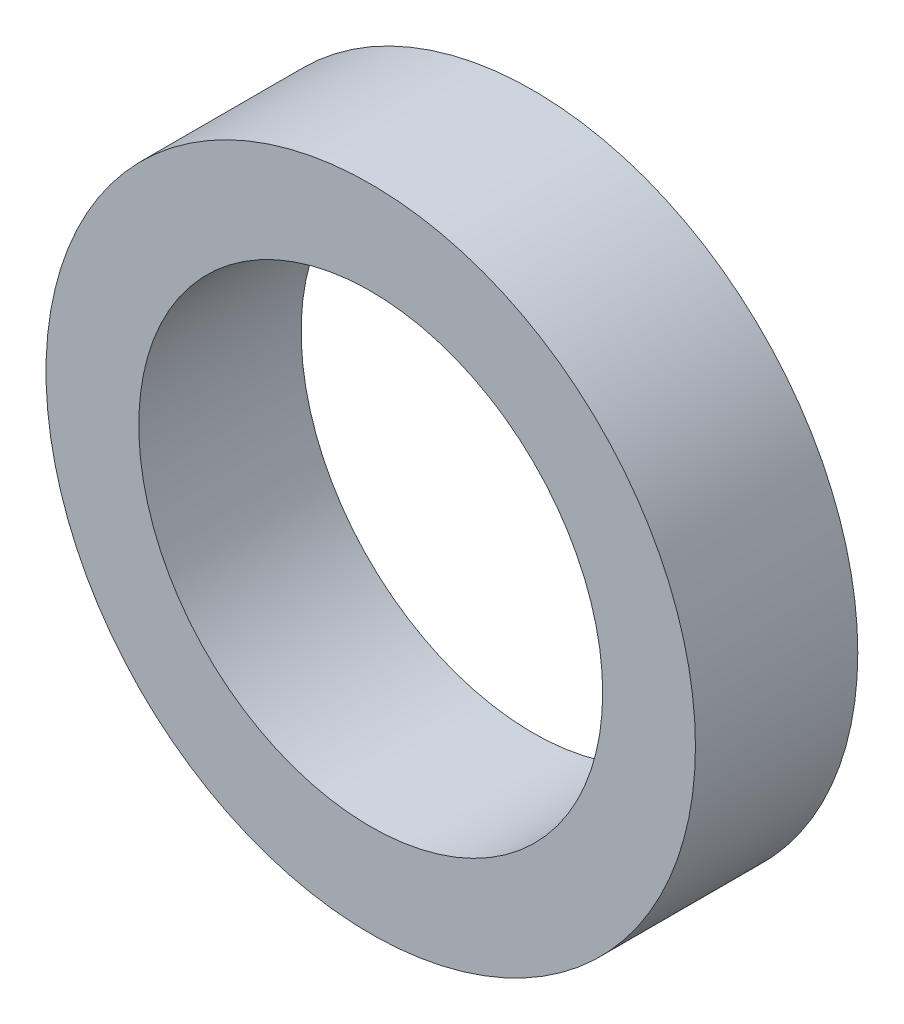
from build123d import *

# Parameters (mm, degrees)
SKETCH1_R           = 20
SKETCH1_R_2         = 14.2875
BOSS_EXTRUDE1_DEPTH = 10


with BuildPart() as part:
    # Sketch1 → Boss-Extrude1 (new body)
    with BuildSketch(Plane.XY):
        Circle(SKETCH1_R)
        Circle(SKETCH1_R_2, mode=Mode.SUBTRACT)
    extrude(amount=BOSS_EXTRUDE1_DEPTH)


solid = part.part
